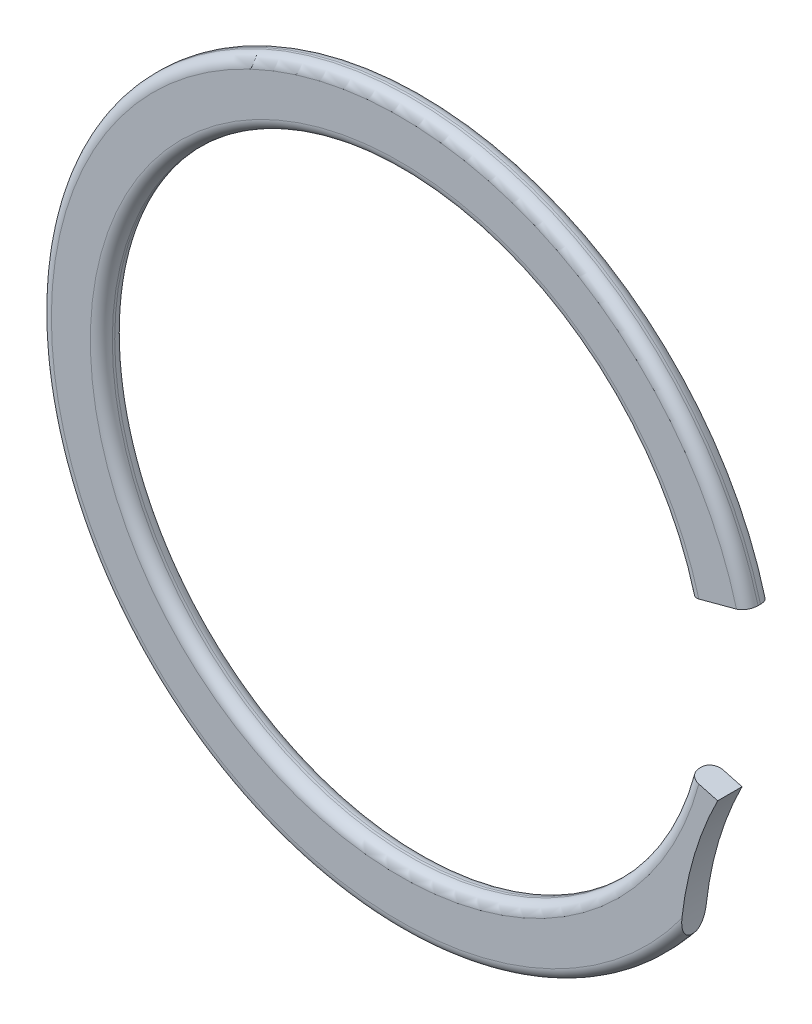
from build123d import *

# Parameters (mm, degrees)
EXTRUDE1_DEPTH = 0.2286
FILLET1_R      = 0.20574


with BuildPart() as part:
    # Sketch2 → Extrude1 (new body, symmetric)
    with BuildSketch(Plane.XY):
        with BuildLine():
            Line((5.409860775, -1.449567826), (5.961887385, -1.59748291))
            ThreePointArc((5.961887385, -1.59748291), (5.473784344, -2.873056661), (5.258707102, -4.221787454))
            ThreePointArc((5.258707102, -4.221787454), (-6.599278553, 1.388168677), (6.513913995, 1.745397994))
            Line((6.513913995, 1.745397994), (5.409860775, 1.449567826))
            ThreePointArc((5.409860775, 1.449567826), (-5.6007, 0), (5.409860775, -1.449567826))
        make_face()
    extrude(amount=EXTRUDE1_DEPTH, both=True)

    # Fillet1
    fillet1_edges = [part.edges().sort_by_distance(p)[0] for p in [
        (-6.599278553, 1.388168677, 0.2286),
        (-5.6007, 0, 0.2286),
        (-6.599278553, 1.388168677, -0.2286),
        (-5.6007, 0, -0.2286),
    ]]
    fillet(fillet1_edges, radius=FILLET1_R)


solid = part.part
